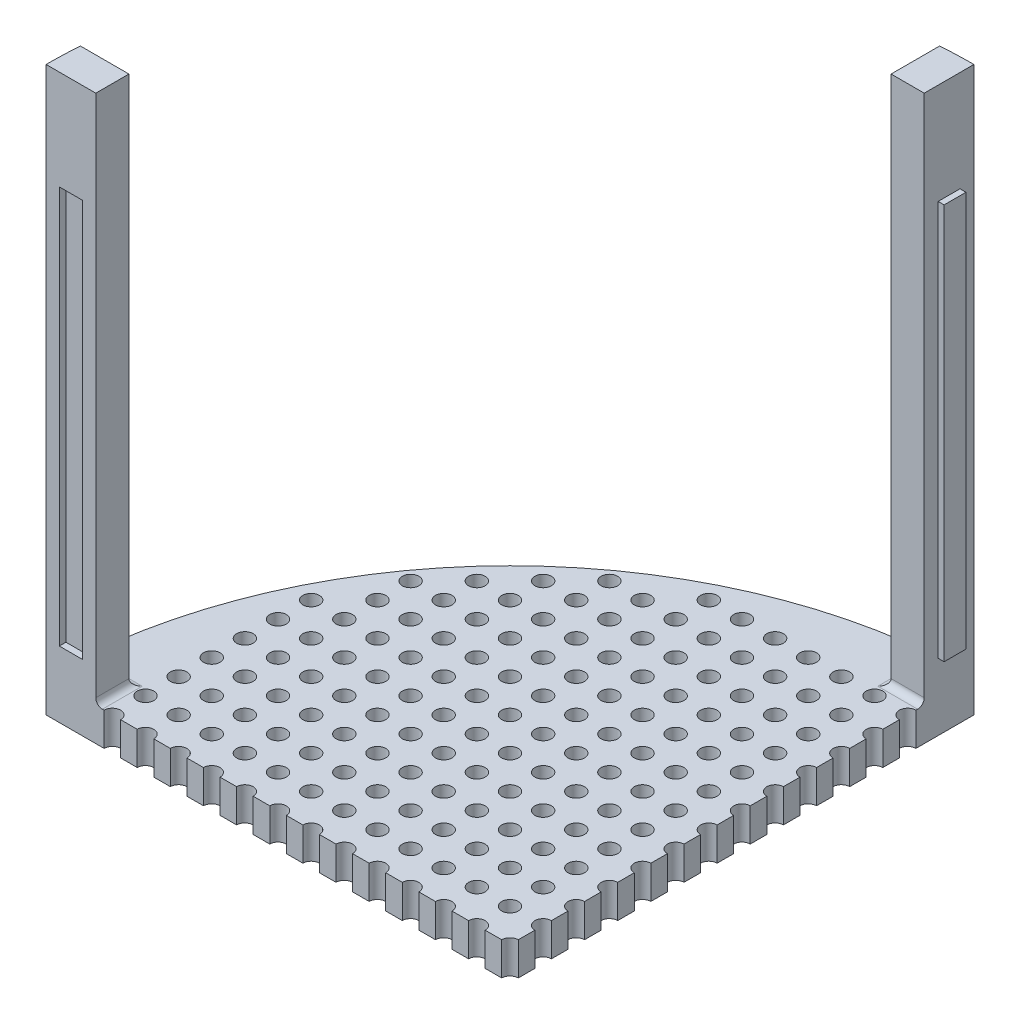
from build123d import *

# Parameters (mm, degrees)
BOSS_EXTRUDE1_DEPTH  = 12.7
BOSS_EXTRUDE2_DEPTH  = 203.2
SKETCH4_R            = 3.174999999999999
CUT_EXTRUDE1_DEPTH   = 254
LPATTERN1_COUNT      = 13
LPATTERN1_PITCH      = 12.699999999999998
LPATTERN1_COUNT_DIR2 = 13
LPATTERN1_PITCH_DIR2 = 12.699999999999998
CUT_EXTRUDE2_DEPTH   = 2.54
BOSS_EXTRUDE3_DEPTH  = 2.286
FILLET1_R            = 2.5399999999999996


with BuildPart() as part:
    # Sketch1 → Boss-Extrude1 (new body)
    with BuildSketch(Plane(origin=(0, 0, 0), x_dir=(1, 0, 0), z_dir=(0, 1, 0))):
        with BuildLine():
            Line((0, 0), (177.79999999999998, 0))
            Line((177.79999999999998, 0), (177.79999999999998, 177.79999999999998))
            ThreePointArc((177.79999999999998, 177.79999999999998), (52.07641430503186, 125.72358569496815), (0, 0))
        make_face()
    extrude(amount=BOSS_EXTRUDE1_DEPTH)

    # Sketch3 → Boss-Extrude2 (add)
    with BuildSketch(Plane(origin=(0, 12.7, 0), x_dir=(1, 0, 0), z_dir=(0, 1, 0))):
        with BuildLine():
            Line((19.05, 1.17e-15), (19.05, 12.700000000000005))
            Line((19.05, 12.700000000000005), (0.45415144413443587, 12.7))
            ThreePointArc((0.45415144413443587, 12.7), (0.11357413517356463, 6.354058811779493), (0, 2.177e-14))
            Line((0, 2.177e-14), (19.05, 1.17e-15))
        make_face()
        with BuildLine():
            Line((177.79999999999998, 158.75), (177.79999999999998, 177.79999999999998))
            ThreePointArc((177.79999999999998, 177.79999999999998), (171.44594118822053, 177.6864258648264), (165.1, 177.34584855586556))
            Line((165.1, 177.34584855586556), (165.1, 158.75))
            Line((165.1, 158.75), (177.79999999999998, 158.75))
        make_face()
    extrude(amount=BOSS_EXTRUDE2_DEPTH)

    # Sketch4 → Cut-Extrude1 (cut)
    with BuildSketch(Plane(origin=(0, 12.7, 0), x_dir=(1, 0, 0), z_dir=(0, 1, 0))):
        with Locations((177.79999999999998, 0)):
            Circle(SKETCH4_R)
    cut_extrude1 = extrude(amount=-CUT_EXTRUDE1_DEPTH, mode=Mode.SUBTRACT)

    # LPattern1: Cut-Extrude1 13 × 13, 6 skipped
    with Locations(*[(-j * LPATTERN1_PITCH_DIR2, 0, -i * LPATTERN1_PITCH) for i in range(LPATTERN1_COUNT) for j in range(LPATTERN1_COUNT_DIR2) if (i, j) not in ((0, 0), (7, 12), (9, 11), (10, 10), (11, 9), (12, 7), (12, 8))]):
        add(cut_extrude1, mode=Mode.SUBTRACT)

    # Sketch5 → Cut-Extrude2 (cut)
    with BuildSketch(Plane.XY):
        Polygon((5.079999999999969, 177.8), (13.969999999999997, 177.8), (13.970000000000018, 25.400000000000002), (5.079999999999992, 25.400000000000006), align=None)
    extrude(amount=-CUT_EXTRUDE2_DEPTH, mode=Mode.SUBTRACT)

    # Sketch6 → Boss-Extrude3 (add)
    with BuildSketch(Plane(origin=(177.79999999999998, 0, 0), x_dir=(0, 0, -1), z_dir=(1, 0, 0))):
        Polygon((164.084, 177.292), (172.46599999999998, 177.292), (172.466, 25.654), (164.08400000000003, 25.654), align=None)
    extrude(amount=BOSS_EXTRUDE3_DEPTH)

    # Fillet1
    fillet1_edges = [part.edges().sort_by_distance(p)[0] for p in [
        (19.05, 12.7, -6.350000000000002),
        (9.752075722067218, 12.7, -12.700000000000003),
        (165.1, 12.7, -168.0479242779328),
        (171.45, 12.7, -158.75),
    ]]
    fillet(fillet1_edges, radius=FILLET1_R)


solid = part.part
